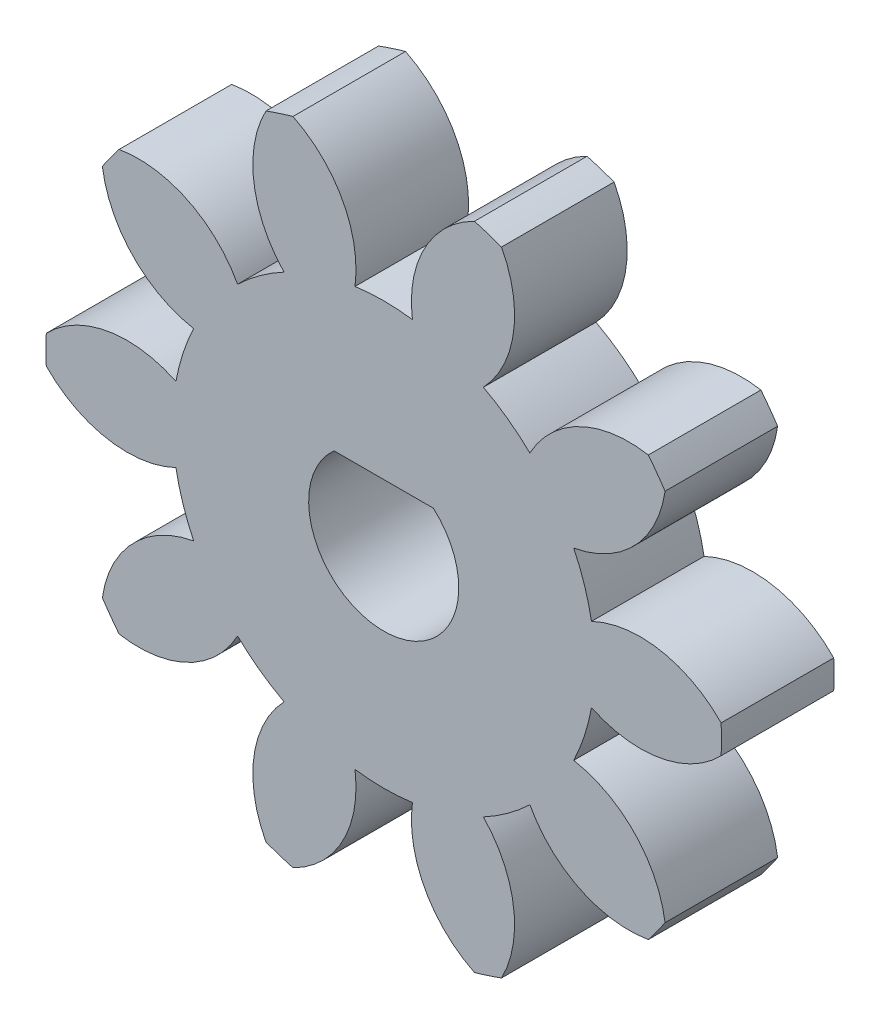
from build123d import *

# Parameters (mm, degrees)
SKETCH1_R           = 9
BOSS_EXTRUDE1_DEPTH = 3
CUT_EXTRUDE1_DEPTH  = 14.076696831
CIRPATTERN1_COUNT   = 10
CUT_EXTRUDE3_DEPTH  = 13.851135167


with BuildPart() as part:
    # Sketch1 → Boss-Extrude1 (new body)
    with BuildSketch(Plane.XY):
        Circle(SKETCH1_R)
    extrude(amount=BOSS_EXTRUDE1_DEPTH)

    # Sketch2 → Cut-Extrude1 (cut, through all)
    with BuildSketch(Plane.XY.offset(3)):
        with BuildLine():
            ThreePointArc((-2.41833102, 8.669006579), (0, 9), (2.41833102, 8.669006579))
            ThreePointArc((2.41833102, 8.669006579), (1.091553585, 7.387918037), (0.76495134, 5.572743889))
            ThreePointArc((0.76495134, 5.572743889), (0, 5.625), (-0.76495134, 5.572743889))
            ThreePointArc((-0.76495134, 5.572743889), (-1.091553585, 7.387918037), (-2.41833102, 8.669006579))
        make_face()
    cut_extrude1 = extrude(amount=-CUT_EXTRUDE1_DEPTH, mode=Mode.SUBTRACT)

    # CirPattern1: Cut-Extrude1 ×10 about axis
    cirpattern1_axis = Axis((0, 0, 0), (0, 0, 1))
    for i in range(1, CIRPATTERN1_COUNT):
        add(cut_extrude1.rotate(cirpattern1_axis, i * 360 / CIRPATTERN1_COUNT), mode=Mode.SUBTRACT)

    # Sketch4 → Cut-Extrude3 (cut, through all)
    with BuildSketch(Plane.XY.offset(3)):
        with BuildLine():
            Line((-1.322875656, 1.5), (1.322875656, 1.5))
            ThreePointArc((1.322875656, 1.5), (0, -2), (-1.322875656, 1.5))
        make_face()
    extrude(amount=-CUT_EXTRUDE3_DEPTH, mode=Mode.SUBTRACT)


solid = part.part
